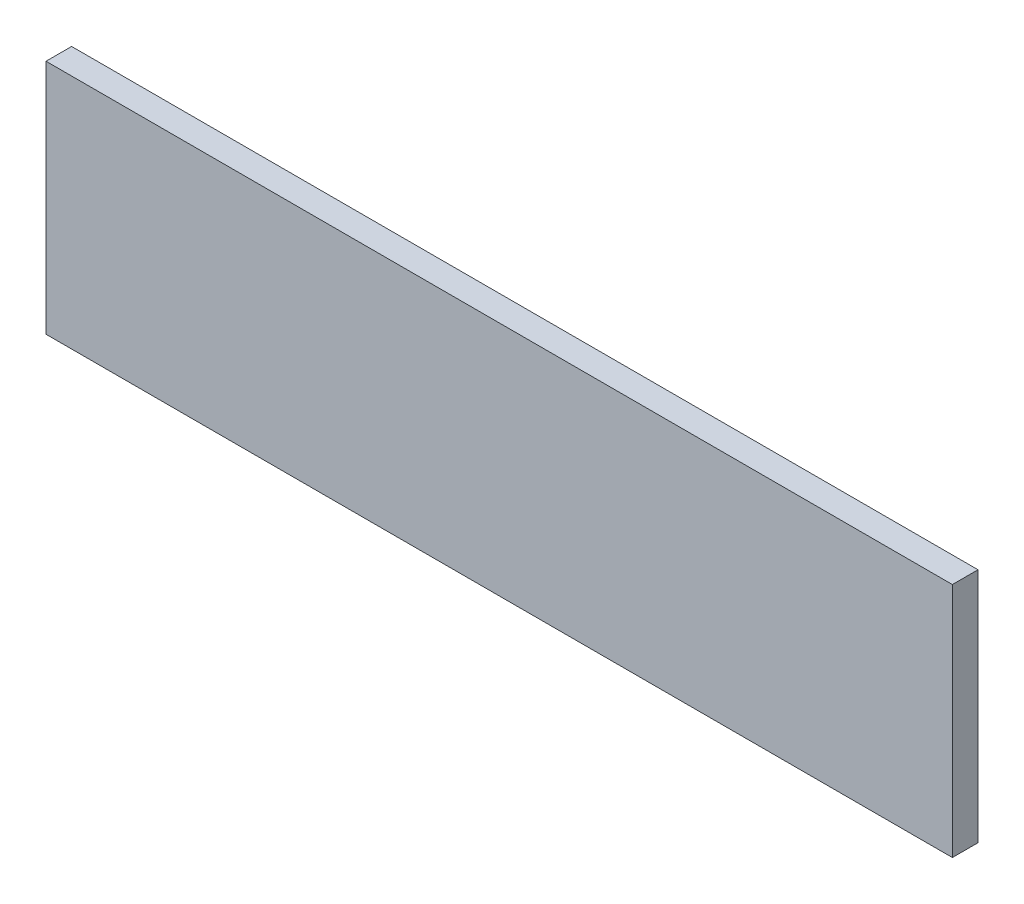
from build123d import *

# Parameters (mm, degrees)
SKETCH1_W           = 58.42
SKETCH1_H           = 15.24
BOSS_EXTRUDE1_DEPTH = 1.651


with BuildPart() as part:
    # Sketch1 → Boss-Extrude1 (new body)
    with BuildSketch(Plane.XY):
        Rectangle(SKETCH1_W, SKETCH1_H)
    extrude(amount=BOSS_EXTRUDE1_DEPTH)


solid = part.part
